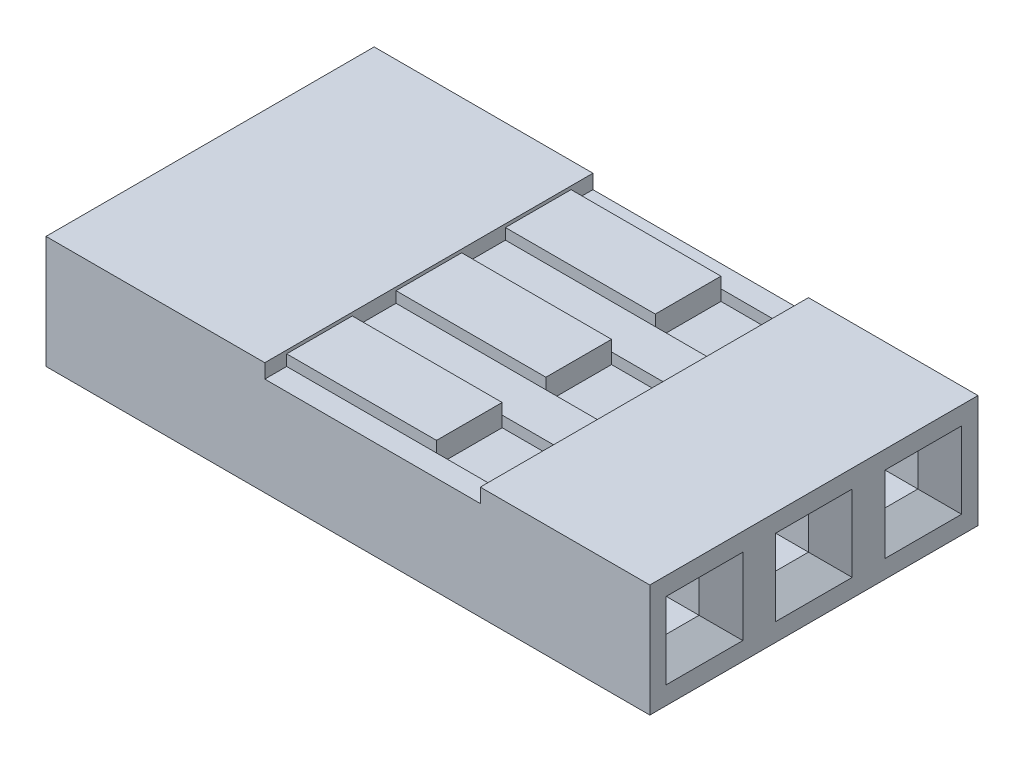
from build123d import *

# Parameters (mm, degrees)
SKETCH1_W           = 14.0208
SKETCH1_H           = 7.62
BOSS_EXTRUDE1_DEPTH = 1.3081
SKETCH2_W           = 0.762
SKETCH2_H           = 0.762
CUT_EXTRUDE1_DEPTH  = 6.35
CHAMFER1_SIZE       = 0.508
SKETCH3_W           = 1.778
SKETCH3_H           = 1.778
CUT_EXTRUDE2_DEPTH  = 0.254
SKETCH4_R           = 0.762
CUT_EXTRUDE3_DEPTH  = 5.08
SKETCH5_W           = 5.0038
SKETCH5_H           = 0.6604
CUT_EXTRUDE4_DEPTH  = 8.62
SKETCH6_W           = 1.524
SKETCH6_H           = 0.381
SKETCH6_H_2         = 0.762
SKETCH6_H_3         = 1.524
CUT_EXTRUDE5_DEPTH  = 0.254
SKETCH7_W           = 1.524
SKETCH7_H           = 0.254
BOSS_EXTRUDE2_DEPTH = 3.4798


with BuildPart() as part:
    # Sketch1 → Boss-Extrude1 (new body, symmetric)
    with BuildSketch(Plane(origin=(0, 0, 0), x_dir=(1, 0, 0), z_dir=(0, 1, 0))):
        Rectangle(SKETCH1_W, SKETCH1_H)
    extrude(amount=BOSS_EXTRUDE1_DEPTH, both=True)

    # Sketch2 → Cut-Extrude1 (cut)
    with BuildSketch(Plane(origin=(7.0104, 0, 0), x_dir=(0, 0, -1), z_dir=(1, 0, 0))):
        Rectangle(SKETCH2_W, SKETCH2_H)
        with Locations((-2.54, 0)):
            Rectangle(SKETCH2_W, SKETCH2_H)
        with Locations((2.54, 0)):
            Rectangle(SKETCH2_W, SKETCH2_H)
    extrude(amount=-CUT_EXTRUDE1_DEPTH, mode=Mode.SUBTRACT)

    # Chamfer1
    chamfer1_edges = [part.edges().sort_by_distance(p)[0] for p in [
        (7.0104, -0.381, 2.54),
        (7.0104, 0, 2.159),
        (7.0104, 0.381, 2.54),
        (7.0104, 0, 2.921),
        (7.0104, -0.381, 0),
        (7.0104, 0, -0.381),
        (7.0104, 0.381, 0),
        (7.0104, 0, 0.381),
        (7.0104, -0.381, -2.54),
        (7.0104, 0, -2.921),
        (7.0104, 0.381, -2.54),
        (7.0104, 0, -2.159),
    ]]
    chamfer(chamfer1_edges, length=CHAMFER1_SIZE)

    # Sketch3 → Cut-Extrude2 (cut)
    with BuildSketch(Plane.ZY.offset(7.0104)):
        with Locations((-2.54, 0)):
            Rectangle(SKETCH3_W, SKETCH3_H)
        Rectangle(SKETCH3_W, SKETCH3_H)
        with Locations((2.54, 0)):
            Rectangle(SKETCH3_W, SKETCH3_H)
    extrude(amount=-CUT_EXTRUDE2_DEPTH, mode=Mode.SUBTRACT)

    # Sketch4 → Cut-Extrude3 (cut)
    with BuildSketch(Plane.ZY.offset(6.7564)):
        with Locations((-2.54, 0)):
            Circle(SKETCH4_R)
        Circle(SKETCH4_R)
        with Locations((2.54, 0)):
            Circle(SKETCH4_R)
    extrude(amount=-CUT_EXTRUDE3_DEPTH, mode=Mode.SUBTRACT)

    # Sketch5 → Cut-Extrude4 (cut, through all)
    with BuildSketch(Plane.XY.offset(3.81)):
        with Locations((0.5715, 1.3081)):
            Rectangle(SKETCH5_W, SKETCH5_H)
    extrude(amount=-CUT_EXTRUDE4_DEPTH, mode=Mode.SUBTRACT)

    # Sketch6 → Cut-Extrude5 (cut)
    with BuildSketch(Plane(origin=(0, 0.9779, 0), x_dir=(1, 0, 0), z_dir=(0, 1, 0))):
        with Locations((2.3114, 3.1115)):
            Rectangle(SKETCH6_W, SKETCH6_H)
        with Locations((2.3114, 2.54)):
            Rectangle(SKETCH6_W, SKETCH6_H_2)
        with Locations((2.3114, 1.9685)):
            Rectangle(SKETCH6_W, SKETCH6_H)
        with Locations((2.3114, 0)):
            Rectangle(SKETCH6_W, SKETCH6_H_3)
        with Locations((2.3114, -2.54)):
            Rectangle(SKETCH6_W, SKETCH6_H_3)
    extrude(amount=-CUT_EXTRUDE5_DEPTH, mode=Mode.SUBTRACT)

    # Sketch7 → Boss-Extrude2 (add)
    with BuildSketch(Plane(origin=(-1.9304, 0, 0), x_dir=(0, 0, -1), z_dir=(1, 0, 0))):
        with Locations((2.54, 1.1049)):
            Rectangle(SKETCH7_W, SKETCH7_H)
        with Locations((0, 1.1049)):
            Rectangle(SKETCH7_W, SKETCH7_H)
        with Locations((-2.54, 1.1049)):
            Rectangle(SKETCH7_W, SKETCH7_H)
    extrude(amount=BOSS_EXTRUDE2_DEPTH)


solid = part.part
